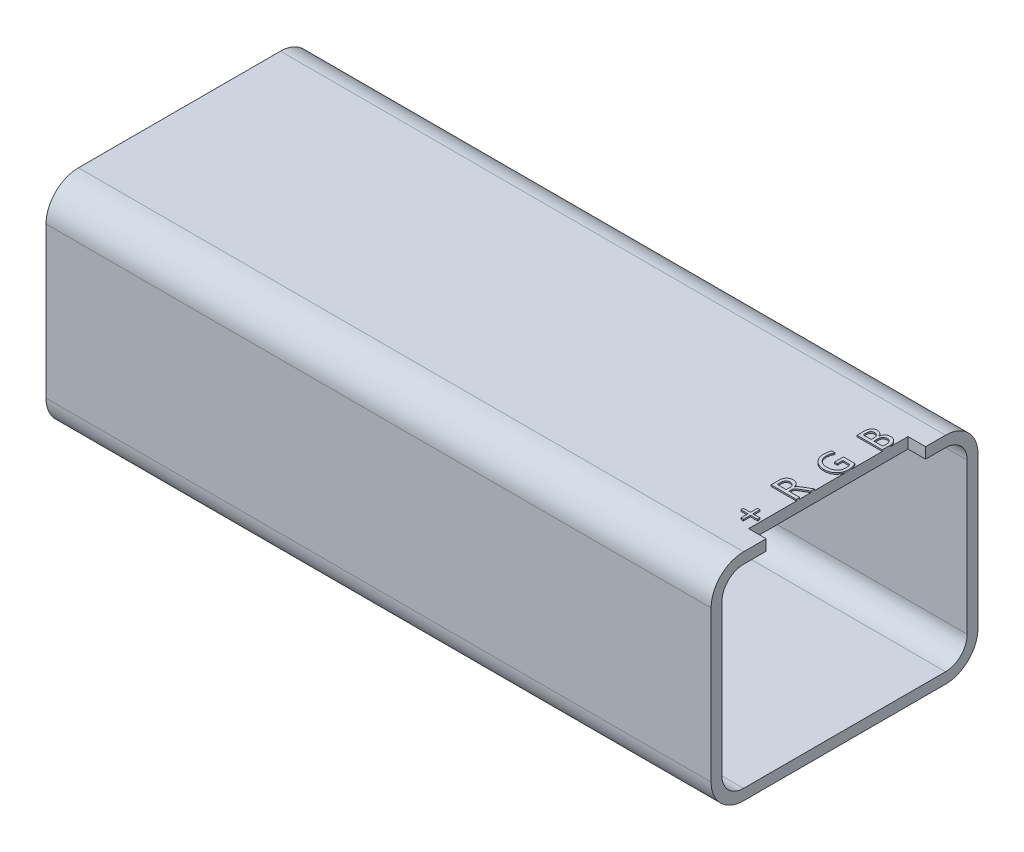
from build123d import *

# Parameters (mm, degrees)
EXTRUDE_1_DEPTH      = 14
EXTRUDE_1_DEPTH_BACK = 78.2
SKETCH_5_W           = 22.100000069
SKETCH_5_H           = 1.5
CUT_EXTRUDE_1_DEPTH  = 2.430073
EXTRUDE_2_DEPTH      = 0.2


with BuildPart() as part:
    # 草图3 → 凸台-拉伸1 (new body, two sides)
    with BuildSketch(Plane(origin=(29.1, 0, 0), x_dir=(0, 0, -1), z_dir=(1, 0, 0))) as extrude_1_sk:
        with BuildLine():
            Line((-4.5, 0), (-4.5, -2.5))
            ThreePointArc((-4.5, -2.5), (-3.181980515, -5.681980515), (0, -7))
            Line((0, -7), (28, -7))
            ThreePointArc((28, -7), (31.181980515, -5.681980515), (32.5, -2.5))
            Line((32.5, -2.5), (32.5, 0))
            Line((32.5, 0), (32.5, 18.4))
            ThreePointArc((32.5, 18.4), (31.181980515, 21.581980515), (28, 22.9))
            Line((28, 22.9), (0, 22.9))
            ThreePointArc((0, 22.9), (-3.181980515, 21.581980515), (-4.5, 18.4))
            Line((-4.5, 18.4), (-4.5, 0))
        make_face()
        with BuildLine():
            Line((-3, 0), (-3, -2.5))
            ThreePointArc((-3, -2.5), (-2.121320344, -4.621320344), (0, -5.5))
            Line((0, -5.5), (28, -5.5))
            ThreePointArc((28, -5.5), (30.121320344, -4.621320344), (31, -2.5))
            Line((31, -2.5), (31, 0))
            Line((31, 0), (31, 18.4))
            ThreePointArc((31, 18.4), (30.121320344, 20.521320344), (28, 21.4))
            Line((28, 21.4), (0, 21.4))
            ThreePointArc((0, 21.4), (-2.121320344, 20.521320344), (-3, 18.4))
            Line((-3, 18.4), (-3, 0))
        make_face(mode=Mode.SUBTRACT)
    extrude(amount=EXTRUDE_1_DEPTH)
    extrude(extrude_1_sk.sketch, amount=-EXTRUDE_1_DEPTH_BACK)

    # 草图5 → 切除-拉伸1 (cut)
    with BuildSketch(Plane(origin=(43.1, 0, 0), x_dir=(0, 0, -1), z_dir=(1, 0, 0))):
        with Locations((14.182655061, 22.15)):
            Rectangle(SKETCH_5_W, SKETCH_5_H)
    extrude(amount=-CUT_EXTRUDE_1_DEPTH, mode=Mode.SUBTRACT)

    # 草图6 → 凸台-拉伸2 (add)
    with BuildSketch(Plane(origin=(0, 22.9, 0), x_dir=(1, 0, 0), z_dir=(0, 1, 0))):
        Polygon((39.389440959, 5.992411124), (39.389440959, 5.010703807), (40.371148276, 5.010703807), (40.371148276, 4.669240392), (39.389440959, 4.669240392), (39.389440959, 3.687533075), (39.047977544, 3.687533075), (39.047977544, 4.669240392), (38.066270227, 4.669240392), (38.066270227, 5.010703807), (39.047977544, 5.010703807), (39.047977544, 5.992411124), align=None)
        with BuildLine():
            Line((40.669928227, 12.266801368), (40.669928227, 11.754606246))
            Line((40.669928227, 11.754606246), (39.684886306, 11.186389782))
            add(Edge.make_bspline(
                [(39.684886306, 11.186389782), (39.661242295, 11.172516573), (39.615362278, 11.145596305), (39.550357084, 11.104536151), (39.49120548, 11.064246213), (39.437844076, 11.02511962), (39.390250998, 10.986565488), (39.349052734, 10.948272569), (39.312500337, 10.912124975), (39.273669804, 10.863959722), (39.23355004, 10.801370847), (39.200261135, 10.718845228), (39.179563178, 10.629637404), (39.177224526, 10.567825438), (39.176025788, 10.536142069)],
                knots=[0, 0, 0, 0, 8.2237e-05, 0.000159577, 0.000230609, 0.000296903, 0.000358046, 0.000414214, 0.000465619, 0.000512074, 0.000599593, 0.000687526, 0.000777804, 0.000872741, 0.000872741, 0.000872741, 0.000872741], degree=3))
            Line((39.176025788, 10.536142069), (39.176025788, 10.21802088))
            Line((39.176025788, 10.21802088), (40.669928227, 10.21802088))
            Line((40.669928227, 10.21802088), (40.669928227, 9.748508685))
            Line((40.669928227, 9.748508685), (37.169928227, 9.748508685))
            Line((37.169928227, 9.748508685), (37.169928227, 10.804244203))
            add(Edge.make_bspline(
                [(37.169928227, 10.804244203), (37.170692697, 10.845179156), (37.172183146, 10.924987989), (37.183866831, 11.041281898), (37.201775754, 11.151250909), (37.229621883, 11.253840047), (37.263218206, 11.350182488), (37.305633982, 11.439131027), (37.354759172, 11.521851296), (37.412613889, 11.596541228), (37.476252036, 11.664156082), (37.547045373, 11.722836624), (37.624082601, 11.772058763), (37.706793284, 11.813442699), (37.795835697, 11.844551826), (37.890892649, 11.866463872), (37.991853029, 11.8799989), (38.061335681, 11.881754975), (38.096948044, 11.882655026)],
                knots=[0, 0, 0, 0, 0.000122779, 0.000239375, 0.000350333, 0.000456616, 0.00055787, 0.000656018, 0.000751751, 0.000845926, 0.000938858, 0.001029799, 0.001121002, 0.001212567, 0.001306643, 0.00140322, 0.001504805, 0.001611614, 0.001611614, 0.001611614, 0.001611614], degree=3))
            add(Edge.make_bspline(
                [(38.096948044, 11.882655026), (38.126321632, 11.882281138), (38.184114324, 11.88154551), (38.268546656, 11.871669658), (38.349313407, 11.857218962), (38.425957717, 11.836755612), (38.498607696, 11.809696073), (38.567422957, 11.777375288), (38.631685038, 11.737968924), (38.693006076, 11.69414162), (38.749669126, 11.643060425), (38.802331825, 11.586191675), (38.851340113, 11.523841113), (38.896038961, 11.455496767), (38.936752368, 11.381207307), (38.973331938, 11.30090622), (39.006219589, 11.214725579), (39.02413787, 11.154506792), (39.033304751, 11.123699234)],
                knots=[0, 0, 0, 0, 8.8074e-05, 0.000173286, 0.00025465, 0.000334084, 0.000410893, 0.000486963, 0.000561765, 0.000636736, 0.00071278, 0.000790172, 0.000869021, 0.00095041, 0.00103488, 0.001122916, 0.001214946, 0.001311346, 0.001311346, 0.001311346, 0.001311346], degree=3))
            Line((39.033304751, 11.123699234), (39.044642403, 11.123699234))
            add(Edge.make_bspline(
                [(39.044642403, 11.123699234), (39.055413376, 11.147125927), (39.076889289, 11.193835699), (39.118966284, 11.257993377), (39.165750602, 11.318517609), (39.211649483, 11.364288286), (39.252926879, 11.40040696), (39.289507948, 11.428851839), (39.32986144, 11.460815831), (39.377003846, 11.492719429), (39.42784432, 11.528369539), (39.48430036, 11.564985678), (39.545624105, 11.60373183), (39.588582226, 11.629742621), (39.610858105, 11.643230484)],
                knots=[0, 0, 0, 0, 7.7251e-05, 0.000154028, 0.000229543, 0.000306413, 0.000348008, 0.000394045, 0.000445402, 0.000502388, 0.00056473, 0.000631692, 0.000704224, 0.000782345, 0.000782345, 0.000782345, 0.000782345], degree=3))
            Line((39.610858105, 11.643230484), (40.669928227, 12.266801368))
        make_face()
        with BuildLine():
            Line((37.554074568, 10.21802088), (38.791879446, 10.21802088))
            Line((38.791879446, 10.21802088), (38.791879446, 10.736218288))
            add(Edge.make_bspline(
                [(38.791879446, 10.736218288), (38.791457875, 10.760702969), (38.790631089, 10.808722283), (38.781462486, 10.878945225), (38.767971476, 10.945862635), (38.747545774, 11.008918883), (38.722334777, 11.068774379), (38.690837862, 11.124780889), (38.653879338, 11.177425457), (38.611254722, 11.225544037), (38.564860241, 11.269931945), (38.513697229, 11.307865339), (38.459601541, 11.34079297), (38.401842222, 11.367927867), (38.340022293, 11.387535133), (38.275096274, 11.402123973), (38.20662764, 11.412083875), (38.159675063, 11.412784184), (38.135629446, 11.413142831)],
                knots=[0, 0, 0, 0, 7.341e-05, 0.000143971, 0.000212118, 0.000277924, 0.000342464, 0.000406658, 0.00047031, 0.000535056, 0.000599219, 0.000662577, 0.000725712, 0.000788968, 0.000853505, 0.000919839, 0.000988503, 0.001060579, 0.001060579, 0.001060579, 0.001060579], degree=3))
            add(Edge.make_bspline(
                [(38.135629446, 11.413142831), (38.113372414, 11.412665085), (38.070040833, 11.411734974), (38.006862475, 11.403499962), (37.947387087, 11.390378426), (37.891687359, 11.371653722), (37.839620885, 11.347529402), (37.791750368, 11.31735127), (37.747239646, 11.282292928), (37.706331864, 11.242377274), (37.670433307, 11.196658874), (37.638586935, 11.14639192), (37.613018718, 11.090754172), (37.591422943, 11.030497853), (37.57421553, 10.96562121), (37.562181803, 10.895553223), (37.555877896, 10.82081135), (37.554687031, 10.769352716), (37.554074568, 10.742887496)],
                knots=[0, 0, 0, 0, 6.6745e-05, 0.000129945, 0.000190781, 0.0002492, 0.000305889, 0.000362514, 0.000418551, 0.000475615, 0.000533526, 0.000592555, 0.000653715, 0.000716791, 0.000784411, 0.000854802, 0.000929794, 0.001009202, 0.001009202, 0.001009202, 0.001009202], degree=3))
            Line((37.554074568, 10.742887496), (37.554074568, 10.21802088))
        make_face(mode=Mode.SUBTRACT)
        with BuildLine():
            add(Edge.make_bspline(
                [(40.418498607, 18.114362343), (40.44198259, 18.070415177), (40.48893067, 17.982558058), (40.548916647, 17.845271629), (40.599467751, 17.703936482), (40.641206971, 17.558303426), (40.672990461, 17.40850846), (40.69544427, 17.254343243), (40.710036329, 17.09625522), (40.711746414, 16.989299412), (40.71261065, 16.93524649)],
                knots=[0, 0, 0, 0, 0.000149441, 0.000298755, 0.000448953, 0.000599466, 0.0007529, 0.000907959, 0.001066638, 0.001228767, 0.001228767, 0.001228767, 0.001228767], degree=3))
            add(Edge.make_bspline(
                [(40.71261065, 16.93524649), (40.711345271, 16.873810221), (40.708865044, 16.753391072), (40.685210846, 16.577603642), (40.649292407, 16.410522847), (40.596899344, 16.252688352), (40.529338538, 16.104042194), (40.446881923, 15.964475562), (40.349515689, 15.834438364), (40.238314085, 15.714465839), (40.114374082, 15.606919742), (39.980336997, 15.51177059), (39.835261498, 15.432447622), (39.68070701, 15.366869827), (39.516030908, 15.315950224), (39.341564648, 15.2804207), (39.157011084, 15.258700071), (39.030697644, 15.255993647), (38.965945253, 15.254606246)],
                knots=[0, 0, 0, 0, 0.000184216, 0.000361076, 0.000531142, 0.000696276, 0.000858935, 0.001020094, 0.001181622, 0.001345377, 0.001509878, 0.001673078, 0.001837548, 0.002004897, 0.002175973, 0.002353726, 0.002538367, 0.002732579, 0.002732579, 0.002732579, 0.002732579], degree=3))
            add(Edge.make_bspline(
                [(38.965945253, 15.254606246), (38.900288861, 15.256074761), (38.77163292, 15.258952367), (38.583192333, 15.283566917), (38.403923931, 15.323443667), (38.232986305, 15.378849723), (38.071506388, 15.451075798), (37.918586105, 15.538980312), (37.77564892, 15.643866817), (37.642080481, 15.76264644), (37.520970378, 15.893919523), (37.415855894, 16.036149219), (37.326366032, 16.187084412), (37.253728712, 16.347100659), (37.196469227, 16.515940217), (37.156104072, 16.69380964), (37.131646896, 16.88076472), (37.128730693, 17.008310513), (37.127244796, 17.073299081)],
                knots=[0, 0, 0, 0, 0.000196904, 0.000385841, 0.000569, 0.000747213, 0.00092395, 0.001098742, 0.001275359, 0.001454861, 0.001634222, 0.001810159, 0.001984472, 0.00215966, 0.002336395, 0.002518401, 0.002706014, 0.00290092, 0.00290092, 0.00290092, 0.00290092], degree=3))
            add(Edge.make_bspline(
                [(37.127244796, 17.073299081), (37.127675854, 17.119332422), (37.128524193, 17.20992796), (37.137606906, 17.342976343), (37.151165556, 17.470804594), (37.171424407, 17.592942284), (37.196361174, 17.709989808), (37.228047923, 17.821401823), (37.26408126, 17.928024032), (37.29391886, 17.995626632), (37.308647235, 18.02899649)],
                knots=[0, 0, 0, 0, 0.000138078, 0.000271744, 0.000399893, 0.000523569, 0.000643, 0.000758703, 0.000870908, 0.000980285, 0.000980285, 0.000980285, 0.000980285], degree=3))
            Line((37.308647235, 18.02899649), (37.77815943, 18.02899649))
            add(Edge.make_bspline(
                [(37.77815943, 18.02899649), (37.756645315, 17.993545162), (37.713608422, 17.92262823), (37.659922582, 17.809611501), (37.613620703, 17.69228474), (37.576542878, 17.569725624), (37.546812141, 17.442588487), (37.526652144, 17.310122125), (37.513409743, 17.172718497), (37.512070607, 17.079333141), (37.511391138, 17.031949996)],
                knots=[0, 0, 0, 0, 0.000124336, 0.000248721, 0.000374797, 0.00050243, 0.000632499, 0.000766158, 0.000904127, 0.001046237, 0.001046237, 0.001046237, 0.001046237], degree=3))
            add(Edge.make_bspline(
                [(37.511391138, 17.031949996), (37.512427577, 16.985419313), (37.514459663, 16.894189314), (37.533881689, 16.760644054), (37.564362865, 16.633254676), (37.607136761, 16.51203669), (37.662129616, 16.39695666), (37.73010863, 16.288586229), (37.809710245, 16.185869842), (37.901795965, 16.091106851), (38.003059097, 16.00461281), (38.113356172, 15.92938227), (38.231406108, 15.865804005), (38.357343257, 15.813477522), (38.491348943, 15.773746766), (38.632836313, 15.745170666), (38.781875436, 15.727534279), (38.88386487, 15.725272932), (38.93593382, 15.724118441)],
                knots=[0, 0, 0, 0, 0.000139516, 0.00027354, 0.000403916, 0.000531953, 0.00065843, 0.000785749, 0.000915018, 0.001047555, 0.001181453, 0.0013139, 0.001447286, 0.00158303, 0.001722287, 0.0018659, 0.002015631, 0.002171805, 0.002171805, 0.002171805, 0.002171805], degree=3))
            add(Edge.make_bspline(
                [(38.93593382, 15.724118441), (38.989330862, 15.725078751), (39.093485903, 15.72695191), (39.244850131, 15.743323206), (39.387441077, 15.769077001), (39.520902333, 15.805351479), (39.64530868, 15.853028165), (39.760638574, 15.910991852), (39.866504052, 15.980093306), (39.962963039, 16.058963897), (40.048873718, 16.147033523), (40.124262684, 16.242687732), (40.187251856, 16.346614397), (40.239492012, 16.457369727), (40.279610535, 16.576012749), (40.308170467, 16.701579311), (40.32489463, 16.834758628), (40.327254031, 16.925861806), (40.328464308, 16.972594051)],
                knots=[0, 0, 0, 0, 0.00016015, 0.000312385, 0.000456144, 0.00059448, 0.000726635, 0.000855185, 0.000980971, 0.001105133, 0.001228225, 0.001349364, 0.001469691, 0.001592012, 0.001716024, 0.001844643, 0.001977741, 0.002117923, 0.002117923, 0.002117923, 0.002117923], degree=3))
            add(Edge.make_bspline(
                [(40.328464308, 16.972594051), (40.3278188, 17.00483355), (40.326548691, 17.068268282), (40.320489134, 17.161917621), (40.307152523, 17.251702617), (40.291193547, 17.338133079), (40.268619397, 17.420083876), (40.243112432, 17.498941339), (40.210782625, 17.573509033), (40.186018428, 17.621201207), (40.173738699, 17.644850148)],
                knots=[0, 0, 0, 0, 9.674e-05, 0.000190347, 0.000281269, 0.000368902, 0.000453834, 0.000536085, 0.000617351, 0.000697284, 0.000697284, 0.000697284, 0.000697284], degree=3))
            Line((40.173738699, 17.644850148), (39.218708211, 17.644850148))
            Line((39.218708211, 17.644850148), (39.218708211, 16.876557465))
            Line((39.218708211, 16.876557465), (38.834561869, 16.876557465))
            Line((38.834561869, 16.876557465), (38.834561869, 18.114362343))
            Line((38.834561869, 18.114362343), (40.418498607, 18.114362343))
        make_face()
        with BuildLine():
            Line((40.669927186, 21.65704527), (37.169927186, 21.65704527))
            Line((37.169927186, 21.65704527), (37.169927186, 22.668097099))
            add(Edge.make_bspline(
                [(37.169927186, 22.668097099), (37.170444221, 22.704812488), (37.171455544, 22.776627961), (37.182956477, 22.881461107), (37.198539028, 22.981224977), (37.223900798, 23.074629423), (37.254214076, 23.162854649), (37.292352715, 23.24500734), (37.337364161, 23.321525495), (37.388354438, 23.39222258), (37.445789621, 23.455552691), (37.507831739, 23.511135819), (37.574340182, 23.558468728), (37.645746956, 23.596565445), (37.721480666, 23.626929305), (37.801901929, 23.648027843), (37.886655955, 23.661143904), (37.944617588, 23.662466857), (37.974233588, 23.663142831)],
                knots=[0, 0, 0, 0, 0.000110092, 0.000215341, 0.000316102, 0.000412676, 0.000505273, 0.000595684, 0.000683871, 0.000771248, 0.00085671, 0.000939843, 0.001020706, 0.001100972, 0.00118209, 0.001264917, 0.001349899, 0.00143869, 0.00143869, 0.00143869, 0.00143869], degree=3))
            add(Edge.make_bspline(
                [(37.974233588, 23.663142831), (37.998039411, 23.662594656), (38.044875346, 23.661516167), (38.114232402, 23.654019102), (38.181434366, 23.641592894), (38.24641348, 23.623228748), (38.309465291, 23.600707257), (38.370045244, 23.572587795), (38.428676682, 23.539558927), (38.484821525, 23.501819583), (38.538303697, 23.459899714), (38.587804058, 23.413691804), (38.633356386, 23.363524968), (38.67453263, 23.309341064), (38.712372839, 23.251934633), (38.744737268, 23.189933894), (38.774402779, 23.124848642), (38.790441205, 23.079278023), (38.798547612, 23.056244965)],
                knots=[0, 0, 0, 0, 7.141e-05, 0.000140494, 0.000209034, 0.000276185, 0.00034285, 0.000409692, 0.000476284, 0.000544539, 0.00061245, 0.000679928, 0.000747445, 0.000815474, 0.000883917, 0.000953434, 0.001025078, 0.001098296, 0.001098296, 0.001098296, 0.001098296], degree=3))
            Line((38.798547612, 23.056244965), (38.807884503, 23.056244965))
            add(Edge.make_bspline(
                [(38.807884503, 23.056244965), (38.811920492, 23.084993604), (38.819856606, 23.141523108), (38.838571335, 23.223651938), (38.863091844, 23.301719499), (38.894670609, 23.374591927), (38.930720846, 23.443753634), (38.973542845, 23.507820702), (39.022664256, 23.567270002), (39.076524397, 23.622758648), (39.135452327, 23.672770183), (39.199428455, 23.715322757), (39.266337932, 23.752457497), (39.337320751, 23.782729488), (39.412638547, 23.805065306), (39.491538627, 23.821878976), (39.574357664, 23.832018167), (39.630836632, 23.833248975), (39.659542277, 23.833874538)],
                knots=[0, 0, 0, 0, 8.7061e-05, 0.00017119, 0.000252393, 0.000332171, 0.000409141, 0.000486089, 0.000562858, 0.000640203, 0.000717824, 0.000794218, 0.000870332, 0.000947132, 0.001025193, 0.001105636, 0.001188937, 0.001275035, 0.001275035, 0.001275035, 0.001275035], degree=3))
            add(Edge.make_bspline(
                [(39.659542277, 23.833874538), (39.696285356, 23.833137169), (39.768551597, 23.831686911), (39.873907848, 23.81555824), (39.974342834, 23.791461201), (40.068707031, 23.75552696), (40.158092059, 23.710738991), (40.242189847, 23.655918293), (40.319523816, 23.589509367), (40.392184797, 23.515395563), (40.457020815, 23.432840635), (40.514257763, 23.344345592), (40.562244287, 23.249935936), (40.601724474, 23.150119584), (40.632460406, 23.044738558), (40.654457264, 22.933853515), (40.667034642, 22.81711037), (40.668948577, 22.737486782), (40.669927186, 22.696774691)],
                knots=[0, 0, 0, 0, 0.000110141, 0.000216625, 0.000319014, 0.000419474, 0.000518793, 0.000618495, 0.000719771, 0.000824, 0.000929408, 0.001034114, 0.001139701, 0.001246579, 0.001355687, 0.001468562, 0.001585296, 0.001707432, 0.001707432, 0.001707432, 0.001707432], degree=3))
            Line((40.669927186, 22.696774691), (40.669927186, 21.65704527))
        make_face()
        with BuildLine():
            Line((37.554073527, 22.126557465), (38.663829625, 22.126557465))
            Line((38.663829625, 22.126557465), (38.663829625, 22.521374538))
            add(Edge.make_bspline(
                [(38.663829625, 22.521374538), (38.663282108, 22.546955022), (38.662218054, 22.596668607), (38.654992162, 22.669195353), (38.642195068, 22.737144015), (38.625317816, 22.801313752), (38.601377731, 22.860502605), (38.574302517, 22.916490499), (38.541586404, 22.968108659), (38.503280497, 23.014636925), (38.46128023, 23.057174182), (38.414562802, 23.09373131), (38.363934953, 23.124694658), (38.309697914, 23.150306633), (38.251345539, 23.169373066), (38.189300316, 23.183455764), (38.123436348, 23.192340158), (38.0780795, 23.193194573), (38.054930997, 23.193630636)],
                knots=[0, 0, 0, 0, 7.6742e-05, 0.000149142, 0.000218338, 0.000284026, 0.000347807, 0.000409546, 0.000470415, 0.00053062, 0.000590039, 0.00064941, 0.000708088, 0.000767758, 0.000828918, 0.000891853, 0.000958445, 0.001027856, 0.001027856, 0.001027856, 0.001027856], degree=3))
            add(Edge.make_bspline(
                [(38.054930997, 23.193630636), (38.034677425, 23.19310324), (37.995366326, 23.192079592), (37.938428894, 23.184623339), (37.885167782, 23.17274161), (37.835691848, 23.155709435), (37.790577507, 23.1324082), (37.74896468, 23.105426967), (37.71202659, 23.07261833), (37.677968695, 23.035806556), (37.649156035, 22.992924235), (37.623519157, 22.945574307), (37.60137476, 22.893679004), (37.584477928, 22.836255856), (37.570118343, 22.774431708), (37.561433537, 22.707188329), (37.555065537, 22.635318062), (37.554410709, 22.585637332), (37.554073527, 22.560055941)],
                knots=[0, 0, 0, 0, 6.0748e-05, 0.000117909, 0.000171946, 0.000224256, 0.000274364, 0.000323936, 0.000372622, 0.000422194, 0.000473991, 0.000527111, 0.000583595, 0.000642876, 0.000706461, 0.000773803, 0.000846081, 0.000922803, 0.000922803, 0.000922803, 0.000922803], degree=3))
            Line((37.554073527, 22.560055941), (37.554073527, 22.126557465))
        make_face(mode=Mode.SUBTRACT)
        with BuildLine():
            Line((39.047975966, 22.126557465), (40.285780844, 22.126557465))
            Line((40.285780844, 22.126557465), (40.285780844, 22.649423319))
            add(Edge.make_bspline(
                [(40.285780844, 22.649423319), (40.285322163, 22.677235171), (40.284432125, 22.731202089), (40.276032226, 22.809605786), (40.263732028, 22.883273731), (40.24585632, 22.952096489), (40.22241083, 23.015993098), (40.193668571, 23.075044698), (40.159684663, 23.129182597), (40.120570737, 23.178185676), (40.077427944, 23.222557833), (40.029138831, 23.260349913), (39.977295952, 23.293107633), (39.920962408, 23.318633478), (39.861075926, 23.339864913), (39.796817878, 23.35418146), (39.728488329, 23.363089034), (39.681579615, 23.363930923), (39.657541515, 23.364362343)],
                knots=[0, 0, 0, 0, 8.3408e-05, 0.000161847, 0.000236294, 0.000307308, 0.000374829, 0.00044015, 0.000503986, 0.000566167, 0.000627947, 0.000689191, 0.000749704, 0.000811469, 0.000874323, 0.000940007, 0.001008583, 0.00108066, 0.00108066, 0.00108066, 0.00108066], degree=3))
            add(Edge.make_bspline(
                [(39.657541515, 23.364362343), (39.632840193, 23.363651624), (39.585059385, 23.362276851), (39.51553167, 23.353678431), (39.450714572, 23.338716486), (39.391058314, 23.316184601), (39.335518532, 23.289081452), (39.285352316, 23.254576704), (39.239539778, 23.214556961), (39.199467483, 23.167613047), (39.162840632, 23.115559319), (39.13273363, 23.05610728), (39.105653855, 22.991456603), (39.084692995, 22.920244104), (39.068116266, 22.843332399), (39.056021218, 22.760240394), (39.049779535, 22.670860782), (39.048589571, 22.609194221), (39.047975966, 22.57739588)],
                knots=[0, 0, 0, 0, 7.4103e-05, 0.000143341, 0.000209826, 0.000273131, 0.000334273, 0.000394761, 0.000455242, 0.000516224, 0.000579494, 0.000645717, 0.000715693, 0.000789538, 0.000868025, 0.00095159, 0.001041206, 0.001136613, 0.001136613, 0.001136613, 0.001136613], degree=3))
            Line((39.047975966, 22.57739588), (39.047975966, 22.126557465))
        make_face(mode=Mode.SUBTRACT)
    extrude(amount=EXTRUDE_2_DEPTH)


solid = part.part
